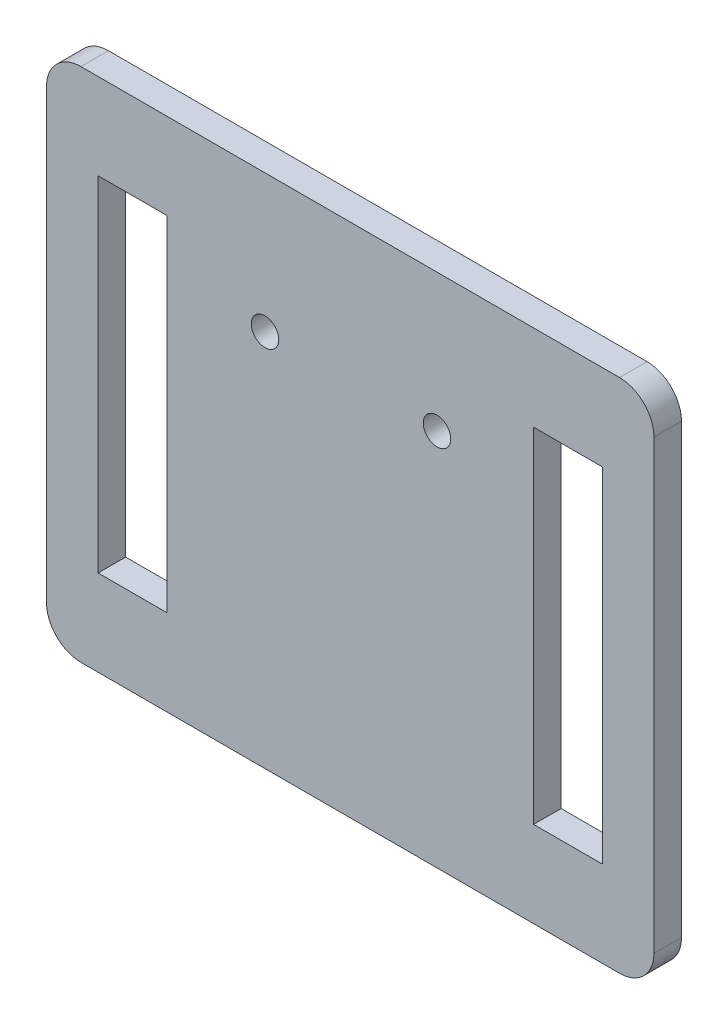
from build123d import *

# Parameters (mm, degrees)
SKETCH_1_W      = 35.318125
SKETCH_1_H      = 30
SKETCH_1_R      = 0.8
SKETCH_1_W_2    = 4
SKETCH_1_H_2    = 20
EXTRUDE_1_DEPTH = 1.6
FILLET_1_R      = 2


with BuildPart() as part:
    # 草图1 → 凸台-拉伸1 (new body)
    with BuildSketch(Plane.XY):
        with Locations((19.3409375, -3.5)):
            Rectangle(SKETCH_1_W, SKETCH_1_H)
        with Locations((14.38454248, 3.5)):
            Circle(SKETCH_1_R, mode=Mode.SUBTRACT)
        with Locations((24.38454248, 3.5)):
            Circle(SKETCH_1_R, mode=Mode.SUBTRACT)
        with Locations((6.681875, -3.5)):
            Rectangle(SKETCH_1_W_2, SKETCH_1_H_2, mode=Mode.SUBTRACT)
        with Locations((32, -3.5)):
            Rectangle(SKETCH_1_W_2, SKETCH_1_H_2, mode=Mode.SUBTRACT)
    extrude(amount=EXTRUDE_1_DEPTH)

    # 圆角1
    fillet_1_edges = [part.edges().sort_by_distance(p)[0] for p in [
        (1.681875, 11.5, 0.8),
        (37, 11.5, 0.8),
        (37, -18.5, 0.8),
        (1.681875, -18.5, 0.8),
    ]]
    fillet(fillet_1_edges, radius=FILLET_1_R)


solid = part.part
